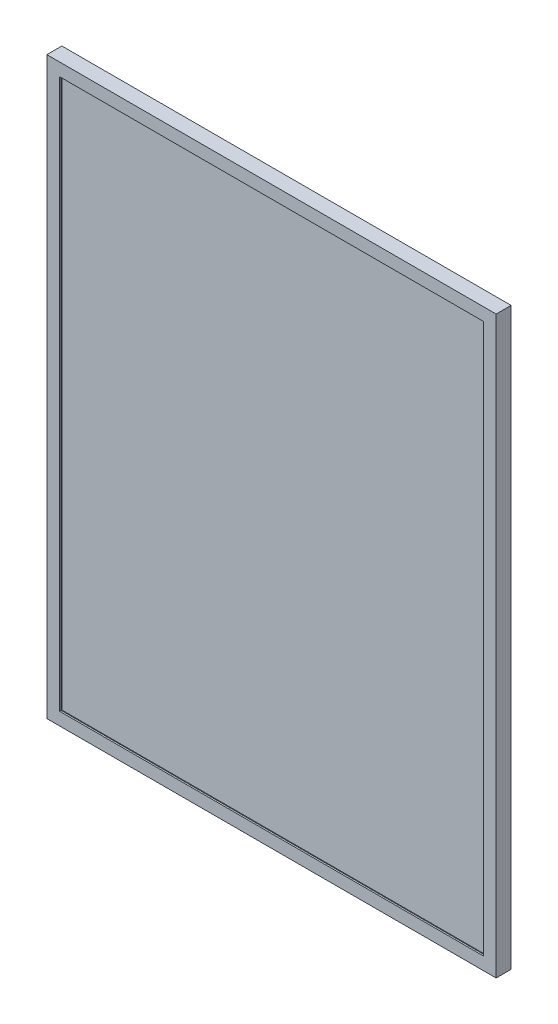
from build123d import *

# Parameters (mm, degrees)
SKETCH1_W           = 600
SKETCH1_H           = 768
BOSS_EXTRUDE1_DEPTH = 20
SHELL1_T            = -2
SKETCH2_W           = 596
SKETCH2_H           = 764
SKETCH2_W_2         = 566
SKETCH2_H_2         = 734
BOSS_EXTRUDE2_DEPTH = 2


with BuildPart() as part:
    # Sketch1 → Boss-Extrude1 (new body)
    with BuildSketch(Plane.XY):
        Rectangle(SKETCH1_W, SKETCH1_H)
    extrude(amount=BOSS_EXTRUDE1_DEPTH)

    # Shell1
    shell1_openings = [part.faces().sort_by_distance(p)[0] for p in [
        (0, 0, 20),
    ]]
    offset(amount=SHELL1_T, openings=shell1_openings, kind=Kind.INTERSECTION)

    # Sketch2 → Boss-Extrude2 (add)
    with BuildSketch(Plane.XY.offset(20)):
        Rectangle(SKETCH2_W, SKETCH2_H)
        Rectangle(SKETCH2_W_2, SKETCH2_H_2, mode=Mode.SUBTRACT)
    extrude(amount=-BOSS_EXTRUDE2_DEPTH)


solid = part.part
